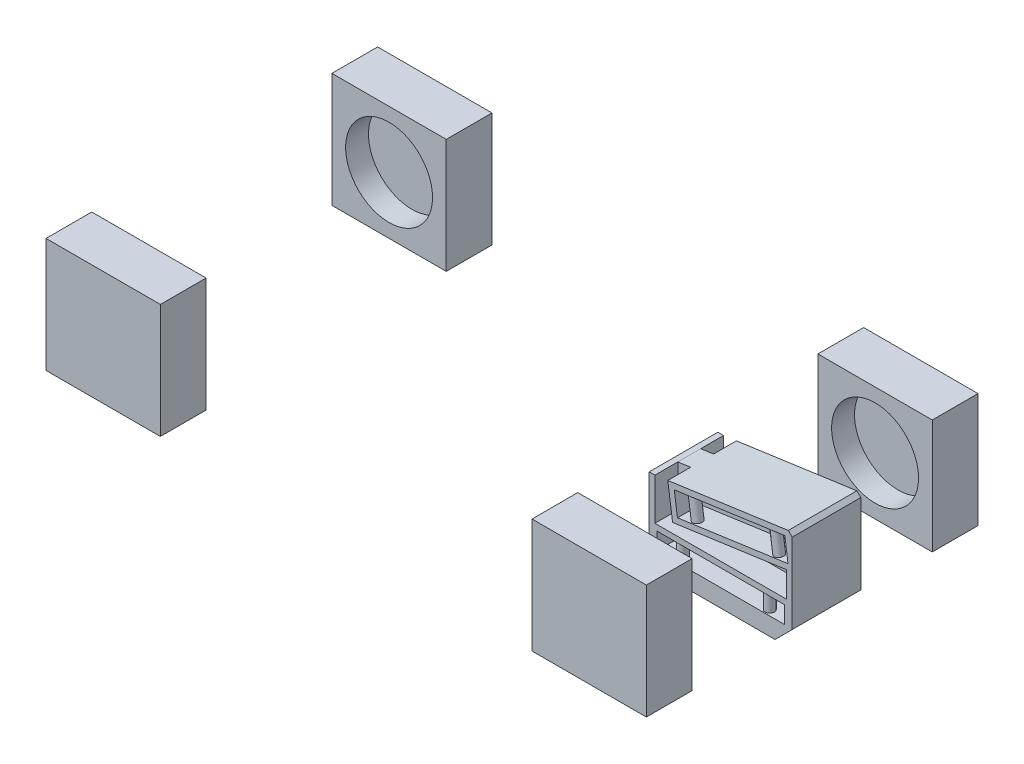
from build123d import *

# Parameters (mm, degrees)
SKETCH1_W                = 100
SKETCH1_H                = 40
BOSS_EXTRUDE1_DEPTH      = 50
BOSS_EXTRUDE1_2_DEPTH    = 50
BOSS_EXTRUDE1_3_DEPTH    = 50
BOSS_EXTRUDE1_4_DEPTH    = 50
SKETCH3_R                = 38
CUT_EXTRUDE5_DEPTH       = 20
SKETCH4_R                = 38
CUT_EXTRUDE6_DEPTH       = 20
SKETCH11_W               = 125
SKETCH11_H               = 100
BOSS_EXTRUDE3_DEPTH      = 30
CHAMFER1_SIZE            = 15
SKETCH17_W               = 111.72522046
SKETCH17_H               = 15
CUT_EXTRUDE8_DEPTH       = 20
SKETCH22_R               = 4
BOSS_EXTRUDE5_DEPTH      = 15
CUT_EXTRUDE9_DEPTH       = 20
SKETCH24_R               = 4
BOSS_EXTRUDE7_DEPTH      = 20
CUT_EXTRUDE12_DEPTH      = 60
CUT_EXTRUDE13_DEPTH      = 20
SKETCH29_R               = 38
CUT_EXTRUDE14_DEPTH      = 230
CUT_EXTRUDE14_DEPTH_BACK = 20


with BuildPart() as part:
    # Sketch1 → Boss-Extrude1 (new body, symmetric)
    with BuildSketch(Plane(origin=(0, 0, 0), x_dir=(1, 0, 0), z_dir=(0, 1, 0))):
        with Locations((212.5, 125)):
            Rectangle(SKETCH1_W, SKETCH1_H)
    extrude(amount=BOSS_EXTRUDE1_DEPTH, both=True)

    # Sketch4 → Cut-Extrude6 (cut)
    with BuildSketch(Plane.XY.offset(-105)):
        with Locations((212.5, 0)):
            Circle(SKETCH4_R)
    extrude(amount=-CUT_EXTRUDE6_DEPTH, mode=Mode.SUBTRACT)


with BuildPart() as body_2:
    # Sketch1 → Boss-Extrude1 2 (new body, symmetric)
    with BuildSketch(Plane(origin=(0, 0, 0), x_dir=(1, 0, 0), z_dir=(0, 1, 0))):
        with Locations((212.5, -125)):
            Rectangle(SKETCH1_W, SKETCH1_H)
    extrude(amount=BOSS_EXTRUDE1_2_DEPTH, both=True)

    # Sketch3 → Cut-Extrude5 (cut)
    with BuildSketch(Plane(origin=(0, 0, 105), x_dir=(-1, 0, 0), z_dir=(0, 0, -1))):
        with Locations((-212.5, 0)):
            Circle(SKETCH3_R)
    extrude(amount=-CUT_EXTRUDE5_DEPTH, mode=Mode.SUBTRACT)


with BuildPart() as body_3:
    # Sketch1 → Boss-Extrude1 3 (new body, symmetric)
    with BuildSketch(Plane(origin=(0, 0, 0), x_dir=(1, 0, 0), z_dir=(0, 1, 0))):
        with Locations((-212.5, -125)):
            Rectangle(SKETCH1_W, SKETCH1_H)
    extrude(amount=BOSS_EXTRUDE1_3_DEPTH, both=True)


with BuildPart() as body_4:
    # Sketch1 → Boss-Extrude1 4 (new body, symmetric)
    with BuildSketch(Plane(origin=(0, 0, 0), x_dir=(1, 0, 0), z_dir=(0, 1, 0))):
        with Locations((-212.5, 125)):
            Rectangle(SKETCH1_W, SKETCH1_H)
    extrude(amount=BOSS_EXTRUDE1_4_DEPTH, both=True)


with BuildPart() as body_5:
    # Sketch11 → Boss-Extrude3 (new body, symmetric)
    with BuildSketch(Plane.XY):
        with Locations((212.5, 0)):
            Rectangle(SKETCH11_W, SKETCH11_H)
    extrude(amount=BOSS_EXTRUDE3_DEPTH, both=True)

    # Chamfer1
    chamfer1_edges = [body_5.edges().sort_by_distance(p)[0] for p in [
        (275, 50, 0),
        (275, -50, 0),
        (150, -50, 0),
        (150, 50, 0),
    ]]
    chamfer(chamfer1_edges, length=CHAMFER1_SIZE)

    # Sketch17 → Cut-Extrude8 (cut)
    with BuildSketch(Plane.XY.offset(30)):
        with Locations((212.5, -27)):
            Rectangle(SKETCH17_W, SKETCH17_H)
    cut_extrude8 = extrude(amount=-CUT_EXTRUDE8_DEPTH, mode=Mode.SUBTRACT)

    # Sketch22 → Boss-Extrude5 (add)
    with BuildSketch(Plane(origin=(0, -34.5, 0), x_dir=(1, 0, 0), z_dir=(0, 1, 0))):
        with Locations((174.566321958, -25)):
            Circle(SKETCH22_R)
        with Locations((250.433678042, -25)):
            Circle(SKETCH22_R)
    boss_extrude5 = extrude(amount=BOSS_EXTRUDE5_DEPTH)

    # Mirror4: Cut-Extrude8, Boss-Extrude5 across plane
    add(cut_extrude8.mirror(Plane.XY), mode=Mode.SUBTRACT)
    add(boss_extrude5.mirror(Plane.XY))

    # Sketch14 → Cut-Extrude9 (cut)
    with BuildSketch(Plane(origin=(0, 0, -30), x_dir=(-1, 0, 0), z_dir=(0, 0, -1))):
        Polygon((-268.580387406, 32.929801142), (-271.370152896, 13.125326686), (-174.692702514, -0.49318237), (-171.902937024, 19.311292087), align=None)
    cut_extrude9 = extrude(amount=-CUT_EXTRUDE9_DEPTH, mode=Mode.SUBTRACT)

    # Sketch24 → Boss-Extrude7 (add)
    with BuildSketch(Plane(origin=(3.467112812, -24.61294592, 0), x_dir=(0.990223723, 0.139488274, 0), z_dir=(-0.139488274, 0.990223723, 0))):
        with Locations((257.746246584, 25)):
            Circle(SKETCH24_R)
        with Locations((185.717810735, 25)):
            Circle(SKETCH24_R)
    boss_extrude7 = extrude(amount=BOSS_EXTRUDE7_DEPTH)

    # Mirror5: Cut-Extrude9, Boss-Extrude7 across plane
    add(cut_extrude9.mirror(Plane.XY), mode=Mode.SUBTRACT)
    add(boss_extrude7.mirror(Plane.XY))

    # Sketch27 → Cut-Extrude12 (cut)
    with BuildSketch(Plane.XY.offset(30)):
        Polygon((150, 21.97961685), (155, 21.97961685), (271.5960345, 38.4039655), (260, 50), (165, 50), (150, 35), align=None)
    extrude(amount=-CUT_EXTRUDE12_DEPTH, mode=Mode.SUBTRACT)

    # Sketch28 → Cut-Extrude13 (cut)
    with BuildSketch(Plane.XY.offset(30)):
        Polygon((155, -14.5), (270, -14.5), (270, 7.882955549), (170.439025272, -6.141742357), (166.254377038, 23.564969329), (155, 21.97961685), align=None)
    cut_extrude13 = extrude(amount=-CUT_EXTRUDE13_DEPTH, mode=Mode.SUBTRACT)

    # Mirror6: Cut-Extrude13 across plane
    add(cut_extrude13.mirror(Plane.XY), mode=Mode.SUBTRACT)


with BuildPart() as cut_extrude14_tool:
    # Sketch29 → Cut-Extrude14 (new body, two sides)
    with BuildSketch(Plane.XY.offset(-105)) as cut_extrude14_sk:
        with Locations((-212.5, 0)):
            Circle(SKETCH29_R)
    extrude(amount=CUT_EXTRUDE14_DEPTH)
    extrude(cut_extrude14_sk.sketch, amount=-CUT_EXTRUDE14_DEPTH_BACK)


with BuildPart() as body_3_1:
    add(body_3.part)

    # Cut-Extrude14: cut by cut_extrude14_tool
    add(cut_extrude14_tool.part, mode=Mode.SUBTRACT)


with BuildPart() as body_4_1:
    add(body_4.part)

    # Cut-Extrude14: cut by cut_extrude14_tool
    add(cut_extrude14_tool.part, mode=Mode.SUBTRACT)


solid = Compound([part.part, body_2.part, body_5.part, body_3_1.part, body_4_1.part])
